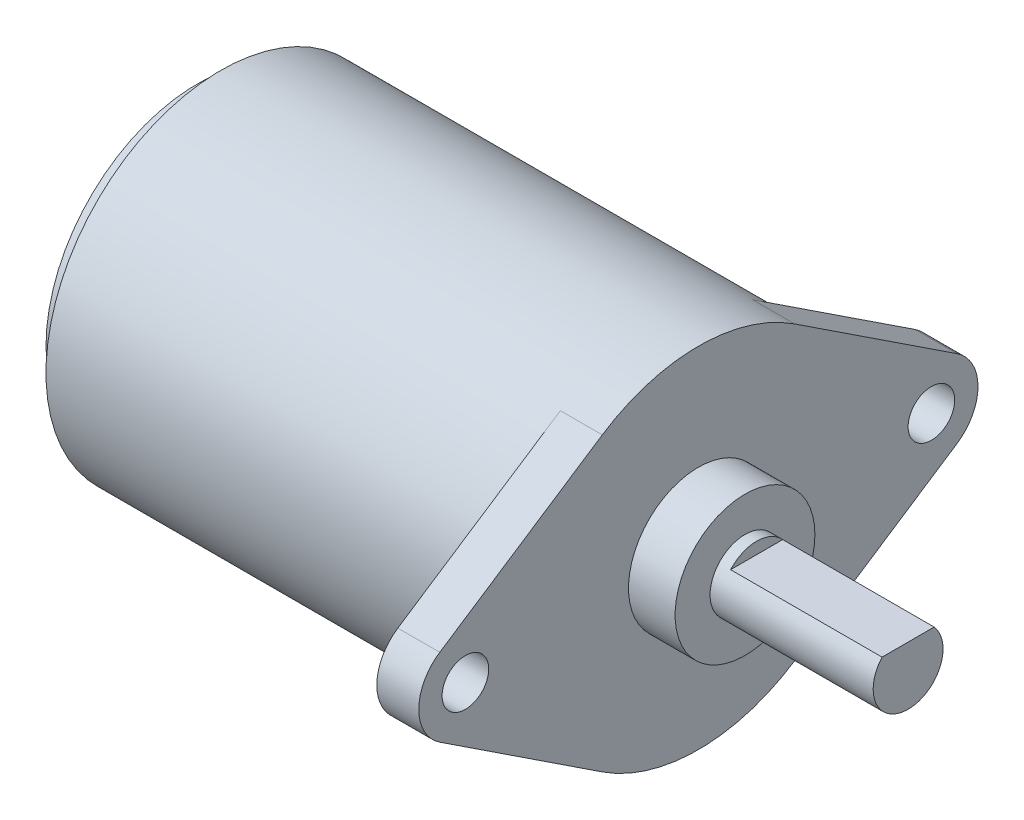
from build123d import *

# Parameters (mm, degrees)
SKETCH_1_R      = 7.5
EXTRUDE_1_DEPTH = 18.7
SKETCH_2_R      = 1
EXTRUDE_2_DEPTH = 1.8
SKETCH_3_R      = 6.5
EXTRUDE_3_DEPTH = 1
SKETCH_4_R      = 2.7
EXTRUDE_4_DEPTH = 1
SKETCH_5_R      = 0.75
EXTRUDE_5_DEPTH = 0.5
SKETCH_6_R      = 3
EXTRUDE_6_DEPTH = 2
SKETCH_7_R      = 1.5
EXTRUDE_7_DEPTH = 0.5
EXTRUDE_8_DEPTH = 6.5


with BuildPart() as part:
    # 草图1 → 凸台-拉伸1 (new body)
    with BuildSketch(Plane(origin=(0, 0, 0), x_dir=(0, 0, -1), z_dir=(1, 0, 0))):
        Circle(SKETCH_1_R)
    extrude(amount=EXTRUDE_1_DEPTH)

    # 草图2 → 凸台-拉伸2 (add)
    with BuildSketch(Plane(origin=(18.7, 0, 0), x_dir=(0, 0, -1), z_dir=(1, 0, 0))):
        with BuildLine():
            Line((4.125, 6.263734908), (11.1, 1.670329309))
            ThreePointArc((11.1, 1.670329309), (12, 0), (11.1, -1.670329309))
            Line((11.1, -1.670329309), (4.125, -6.263734908))
            ThreePointArc((4.125, -6.263734908), (0, -7.5), (-4.125, -6.263734908))
            Line((-4.125, -6.263734908), (-11.1, -1.670329309))
            ThreePointArc((-11.1, -1.670329309), (-12, 0), (-11.1, 1.670329309))
            Line((-11.1, 1.670329309), (-4.125, 6.263734908))
            ThreePointArc((-4.125, 6.263734908), (0, 7.5), (4.125, 6.263734908))
        make_face()
        with Locations((10, 0)):
            Circle(SKETCH_2_R, mode=Mode.SUBTRACT)
        with Locations((-10, 0)):
            Circle(SKETCH_2_R, mode=Mode.SUBTRACT)
    extrude(amount=EXTRUDE_2_DEPTH)

    # 草图3 → 凸台-拉伸3 (add)
    with BuildSketch(Plane.ZY):
        Circle(SKETCH_3_R)
    extrude(amount=EXTRUDE_3_DEPTH)

    # 草图4 → 凸台-拉伸4 (add)
    with BuildSketch(Plane.ZY.offset(1)):
        Circle(SKETCH_4_R)
    extrude(amount=EXTRUDE_4_DEPTH)

    # 草图5 → 凸台-拉伸5 (add)
    with BuildSketch(Plane.ZY.offset(2)):
        Circle(SKETCH_5_R)
    extrude(amount=EXTRUDE_5_DEPTH)

    # 草图6 → 凸台-拉伸6 (add)
    with BuildSketch(Plane(origin=(20.5, 0, 0), x_dir=(0, 0, -1), z_dir=(1, 0, 0))):
        Circle(SKETCH_6_R)
    extrude(amount=EXTRUDE_6_DEPTH)

    # 草图7 → 凸台-拉伸7 (add)
    with BuildSketch(Plane(origin=(22.5, 0, 0), x_dir=(0, 0, -1), z_dir=(1, 0, 0))):
        Circle(SKETCH_7_R)
    extrude(amount=EXTRUDE_7_DEPTH)

    # 草图8 → 凸台-拉伸8 (add)
    with BuildSketch(Plane(origin=(23, 0, 0), x_dir=(0, 0, -1), z_dir=(1, 0, 0))):
        with BuildLine():
            Line((0, 1), (1.118033989, 1))
            ThreePointArc((1.118033989, 1), (0, -1.5), (-1.118033989, 1))
            Line((-1.118033989, 1), (0, 1))
        make_face()
    extrude(amount=EXTRUDE_8_DEPTH)


solid = part.part
